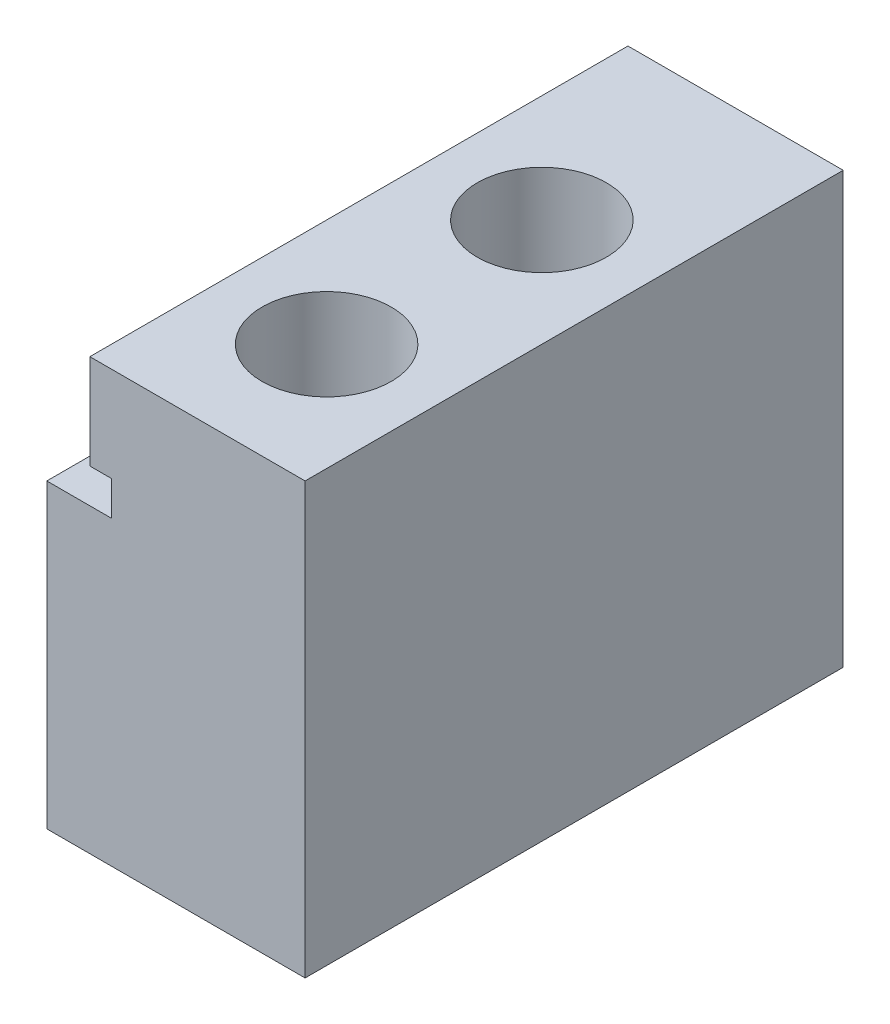
from build123d import *

# Parameters (mm, degrees)
SKETCH_1_W          = 12
SKETCH_1_H          = 25
SKETCH_1_R          = 1.75
EXTRUDE_1_DEPTH     = 20
CUT_EXTRUDE_1_DEPTH = 26
SKETCH_3_R          = 3
CUT_EXTRUDE_2_DEPTH = 10
SKETCH_4_R          = 3.75
CUT_EXTRUDE_3_DEPTH = 3


with BuildPart() as part:
    # Эскиз1 → Бобышка-Вытянуть1 (new body)
    with BuildSketch(Plane(origin=(0, 0, 0), x_dir=(1, 0, 0), z_dir=(0, 1, 0))):
        with Locations((6, 12.5)):
            Rectangle(SKETCH_1_W, SKETCH_1_H)
        with Locations((7, 6)):
            Circle(SKETCH_1_R, mode=Mode.SUBTRACT)
        with Locations((7, 16)):
            Circle(SKETCH_1_R, mode=Mode.SUBTRACT)
    extrude(amount=EXTRUDE_1_DEPTH)

    # Эскиз2 → Вырез-Вытянуть1 (cut, through all)
    with BuildSketch(Plane.XY):
        Polygon((-54.72135955, 14), (0, 14), (3, 14), (3, 15.6), (2, 15.6), (2, 20), (2, 74.72135955), (-77.977073961, 149.429969527), (-134.698433511, 88.708609977), align=None)
    extrude(amount=-CUT_EXTRUDE_1_DEPTH, mode=Mode.SUBTRACT)

    # Эскиз3 → Вырез-Вытянуть2 (cut)
    with BuildSketch(Plane(origin=(0, 20, 0), x_dir=(1, 0, 0), z_dir=(0, 1, 0))):
        with Locations((7, 16)):
            Circle(SKETCH_3_R)
        with Locations((7, 6)):
            Circle(SKETCH_3_R)
    extrude(amount=-CUT_EXTRUDE_2_DEPTH, mode=Mode.SUBTRACT)

    # Эскиз4 → Вырез-Вытянуть3 (cut)
    with BuildSketch(Plane.XZ):
        with Locations((7, -16)):
            Circle(SKETCH_4_R)
        with Locations((7, -6)):
            Circle(SKETCH_4_R)
    extrude(amount=-CUT_EXTRUDE_3_DEPTH, mode=Mode.SUBTRACT)


solid = part.part
